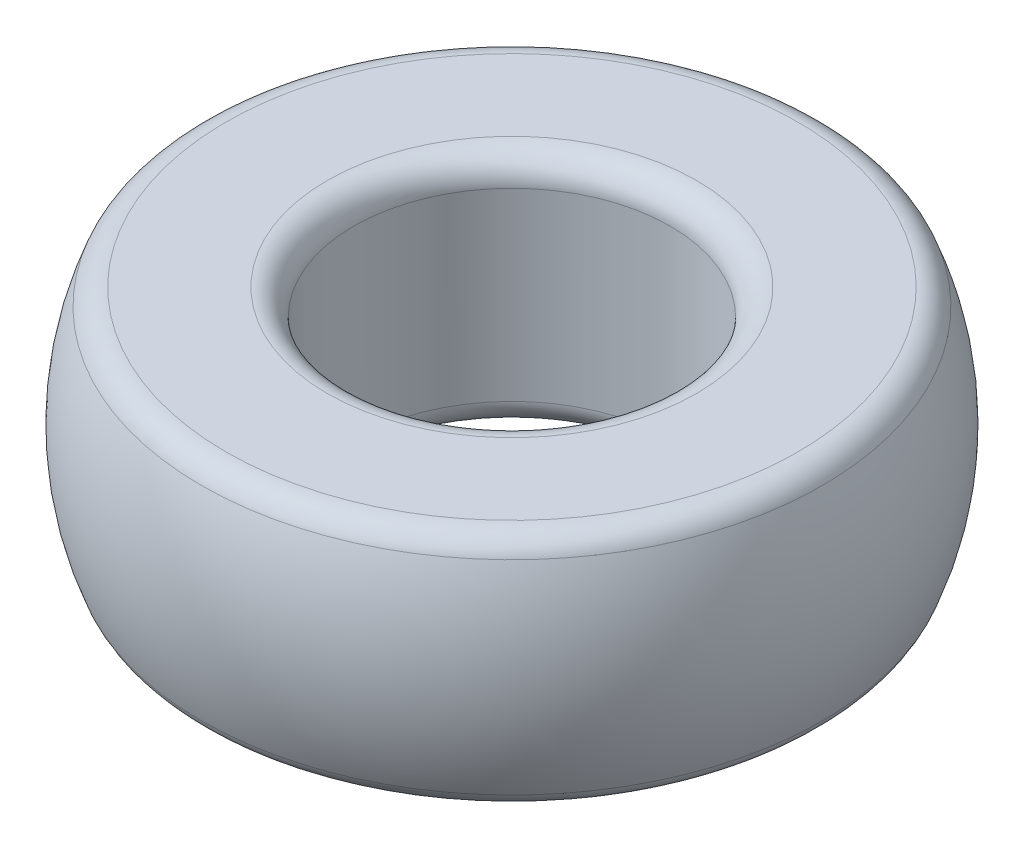
from build123d import *

# Parameters (mm, degrees)
FILLET1_R = 1


with BuildPart() as part:
    # Sketch1 → Revolve1 (revolve)
    with BuildSketch(Plane.XY):
        with BuildLine():
            Line((11.5, 4.5), (6, 4.5))
            Line((6, 4.5), (6, -4.5))
            Line((6, -4.5), (11.5, -4.5))
            ThreePointArc((11.5, -4.5), (12.5, 0), (11.5, 4.5))
        make_face()
    revolve(axis=Axis((0, -5.957115494, 0), (0, 1, 0)))

    # Fillet1
    fillet1_edges = [part.edges().sort_by_distance(p)[0] for p in [
        (-11.5, -4.5, 0),
        (-11.5, 4.5, 0),
        (-6, 4.5, 0),
        (-6, -4.5, 0),
    ]]
    fillet(fillet1_edges, radius=FILLET1_R)


solid = part.part
